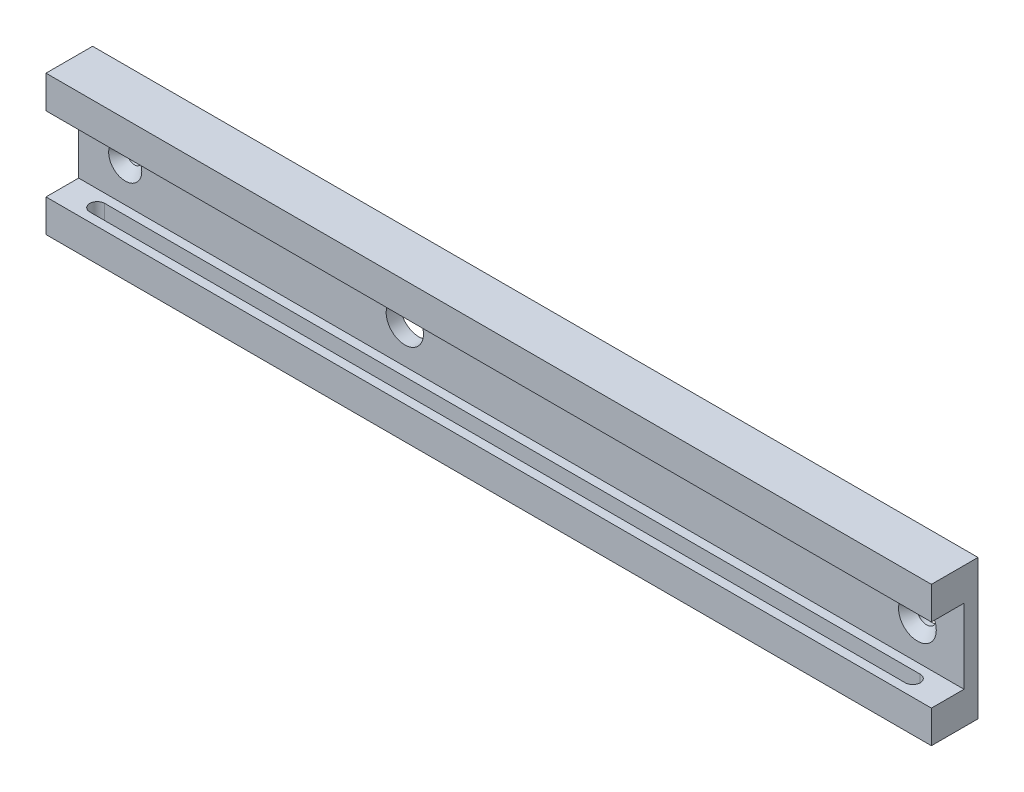
from build123d import *

# Parameters (mm, degrees)
SKETCH1_W           = 190
SKETCH1_H           = 30
BOSS_EXTRUDE1_DEPTH = 10
SKETCH2_W           = 7
SKETCH2_H           = 16
CUT_EXTRUDE1_DEPTH  = 191
CUT_EXTRUDE2_REACH  = 32
SKETCH4_R           = 2.05
SKETCH4_R_2         = 1.55
SKETCH4_R_3         = 4
CUT_EXTRUDE3_DEPTH  = 4
CHAMFER1_SIZE       = 2
CHAMFER2_SIZE       = 2


with BuildPart() as part:
    # Sketch1 → Boss-Extrude1 (new body)
    with BuildSketch(Plane.XY):
        with Locations((95, 15)):
            Rectangle(SKETCH1_W, SKETCH1_H)
    extrude(amount=BOSS_EXTRUDE1_DEPTH)

    # Sketch2 → Cut-Extrude1 (cut, through all)
    with BuildSketch(Plane(origin=(190, 0, 0), x_dir=(0, 0, -1), z_dir=(1, 0, 0))):
        with Locations((-6.5, 15)):
            Rectangle(SKETCH2_W, SKETCH2_H)
    extrude(amount=-CUT_EXTRUDE1_DEPTH, mode=Mode.SUBTRACT)

    # Sketch3 → Cut-Extrude2 (cut, up to next)
    with BuildSketch(Plane.XZ, mode=Mode.PRIVATE) as cut_extrude2_sk1:
        with BuildLine():
            Line((7.5, 8.1), (182.5, 8.1))
            ThreePointArc((182.5, 8.1), (184.1, 6.5), (182.5, 4.9))
            Line((182.5, 4.9), (7.5, 4.9))
            ThreePointArc((7.5, 4.9), (5.9, 6.5), (7.5, 8.1))
        make_face()
    cut_extrude2_tool1 = extrude(cut_extrude2_sk1.sketch, amount=-CUT_EXTRUDE2_REACH, mode=Mode.PRIVATE) & part.part
    add(cut_extrude2_tool1.solids().sort_by_distance((95, 0, 6.5))[0], mode=Mode.SUBTRACT)

    # Sketch4 → Cut-Extrude3 (cut, through all)
    with BuildSketch(Plane.XY.offset(3)):
        with Locations((180, 15)):
            Circle(SKETCH4_R)
        with Locations((10, 15)):
            Circle(SKETCH4_R_2)
        with Locations((70, 15)):
            Circle(SKETCH4_R_3)
    extrude(amount=-CUT_EXTRUDE3_DEPTH, mode=Mode.SUBTRACT)

    # Chamfer1
    chamfer1_edges = [part.edges().sort_by_distance(p)[0] for p in [
        (177.95, 15, 3),
    ]]
    chamfer(chamfer1_edges, length=CHAMFER1_SIZE)

    # Chamfer2
    chamfer2_edges = [part.edges().sort_by_distance(p)[0] for p in [
        (8.45, 15, 3),
    ]]
    chamfer(chamfer2_edges, length=CHAMFER2_SIZE)


solid = part.part
